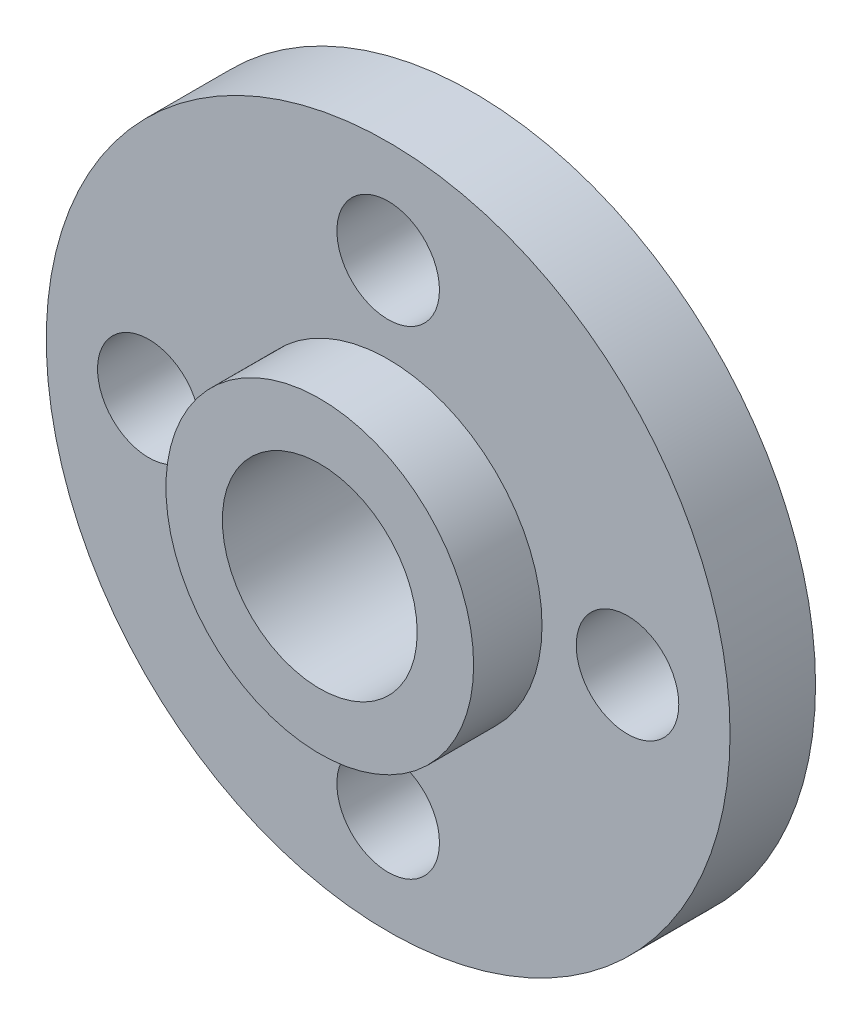
from build123d import *

# Parameters (mm, degrees)
ESQUISSE1_R             = 10
ESQUISSE1_R_2           = 2.85
BOSS_EXTRU_1_DEPTH      = 2.5
ESQUISSE2_R             = 4.5
ESQUISSE2_R_2           = 2.85
BOSS_EXTRU_2_DEPTH      = 2
ESQUISSE3_R             = 1.5
ENL_V_MAT_EXTRU_1_DEPTH = 3.5


with BuildPart() as part:
    # Esquisse1 → Boss.-Extru.1 (new body)
    with BuildSketch(Plane.XY):
        Circle(ESQUISSE1_R)
        Circle(ESQUISSE1_R_2, mode=Mode.SUBTRACT)
    extrude(amount=BOSS_EXTRU_1_DEPTH)

    # Esquisse2 → Boss.-Extru.2 (add)
    with BuildSketch(Plane.XY.offset(2.5)):
        Circle(ESQUISSE2_R)
        Circle(ESQUISSE2_R_2, mode=Mode.SUBTRACT)
    extrude(amount=BOSS_EXTRU_2_DEPTH)

    # Esquisse3 → Enlèv. mat.-Extru.1 (cut, through all)
    with BuildSketch(Plane.XY.offset(2.5)):
        with Locations((0, 7)):
            Circle(ESQUISSE3_R)
        with Locations((0, -7)):
            Circle(ESQUISSE3_R)
        with Locations((7, 0)):
            Circle(ESQUISSE3_R)
        with Locations((-7, 0)):
            Circle(ESQUISSE3_R)
    extrude(amount=-ENL_V_MAT_EXTRU_1_DEPTH, mode=Mode.SUBTRACT)


solid = part.part
